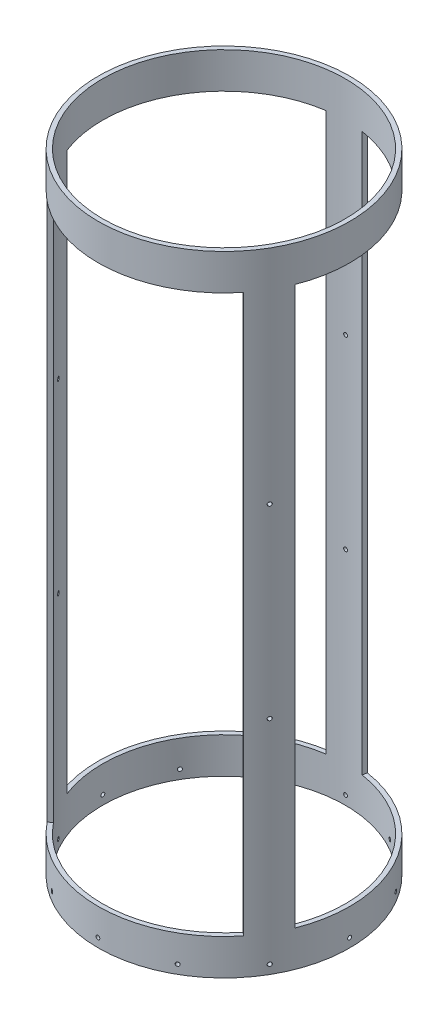
from build123d import *

# Parameters (mm, degrees)
SKETCH1_R           = 88.9
SKETCH1_R_2         = 85.725
BOSS_EXTRUDE1_DEPTH = 222.25
CUT_EXTRUDE5_START  = -25.4
CUT_EXTRUDE5_DEPTH  = 393.7
CIRPATTERN5_COUNT   = 3
CUT_EXTRUDE2_START  = 85.711492
SKETCH3_R           = 1.35255
CUT_EXTRUDE2_DEPTH  = 3.188508
CIRPATTERN2_COUNT   = 12
CUT_EXTRUDE4_START  = -177.8
SKETCH5_R           = 1.35255
CUT_EXTRUDE4_DEPTH  = 3.188508
CIRPATTERN4_COUNT   = 3


with BuildPart() as part:
    # Sketch1 → Boss-Extrude1 (new body, symmetric)
    with BuildSketch(Plane(origin=(0, 0, 0), x_dir=(1, 0, 0), z_dir=(0, 1, 0))):
        Circle(SKETCH1_R)
        Circle(SKETCH1_R_2, mode=Mode.SUBTRACT)
    extrude(amount=BOSS_EXTRUDE1_DEPTH, both=True)

    # Sketch6 → Cut-Extrude5 (cut)
    with BuildSketch(Plane(origin=(0, -222.25, 0), x_dir=(-1, 0, 0), z_dir=(0, -1, 0)).offset(CUT_EXTRUDE5_START)):
        with BuildLine():
            Line((82.79008563, -32.388450433), (79.833296857, -31.23172006))
            ThreePointArc((79.833296857, -31.23172006), (74.185462692, 42.956870815), (12.653594621, 84.785978606))
            Line((12.653594621, 84.785978606), (13.122246274, 87.926200036))
            ThreePointArc((13.122246274, 87.926200036), (76.933072421, 44.54786603), (82.79008563, -32.388450433))
        make_face()
    cut_extrude5 = extrude(amount=-CUT_EXTRUDE5_DEPTH, mode=Mode.SUBTRACT)

    # CirPattern5: Cut-Extrude5 ×3 about axis
    cirpattern5_axis = Axis((0, 0, 0), (0, 1, 0))
    for i in range(1, CIRPATTERN5_COUNT):
        add(cut_extrude5.rotate(cirpattern5_axis, i * 360 / CIRPATTERN5_COUNT), mode=Mode.SUBTRACT)

    # Sketch3 → Cut-Extrude2 (cut)
    with BuildSketch(Plane(origin=(0, 0, 0), x_dir=(-1, 0, 0), z_dir=(0, 0, -1)).offset(CUT_EXTRUDE2_START)):
        with Locations((-0.169185452, -215.9)):
            Circle(SKETCH3_R)
    cut_extrude2 = extrude(amount=CUT_EXTRUDE2_DEPTH, mode=Mode.SUBTRACT)

    # CirPattern2: Cut-Extrude2 ×12 about axis
    cirpattern2_axis = Axis((0, 222.25, 0), (0, -1, 0))
    for i in range(1, CIRPATTERN2_COUNT):
        add(cut_extrude2.rotate(cirpattern2_axis, i * 360 / CIRPATTERN2_COUNT), mode=Mode.SUBTRACT)

    # Sketch5 → Cut-Extrude4 (cut)
    with BuildSketch(Plane.XY.offset(88.9).offset(CUT_EXTRUDE4_START)):
        with Locations((0.169185452, 65.616666667)):
            Circle(SKETCH5_R)
        with Locations((0.169185452, -65.616666667)):
            Circle(SKETCH5_R)
    cut_extrude4 = extrude(amount=CUT_EXTRUDE4_DEPTH, mode=Mode.SUBTRACT)

    # CirPattern4: Cut-Extrude4 ×3 about axis
    cirpattern4_axis = Axis((0, 222.25, 0), (0, -1, 0))
    for i in range(1, CIRPATTERN4_COUNT):
        add(cut_extrude4.rotate(cirpattern4_axis, i * 360 / CIRPATTERN4_COUNT), mode=Mode.SUBTRACT)


solid = part.part
